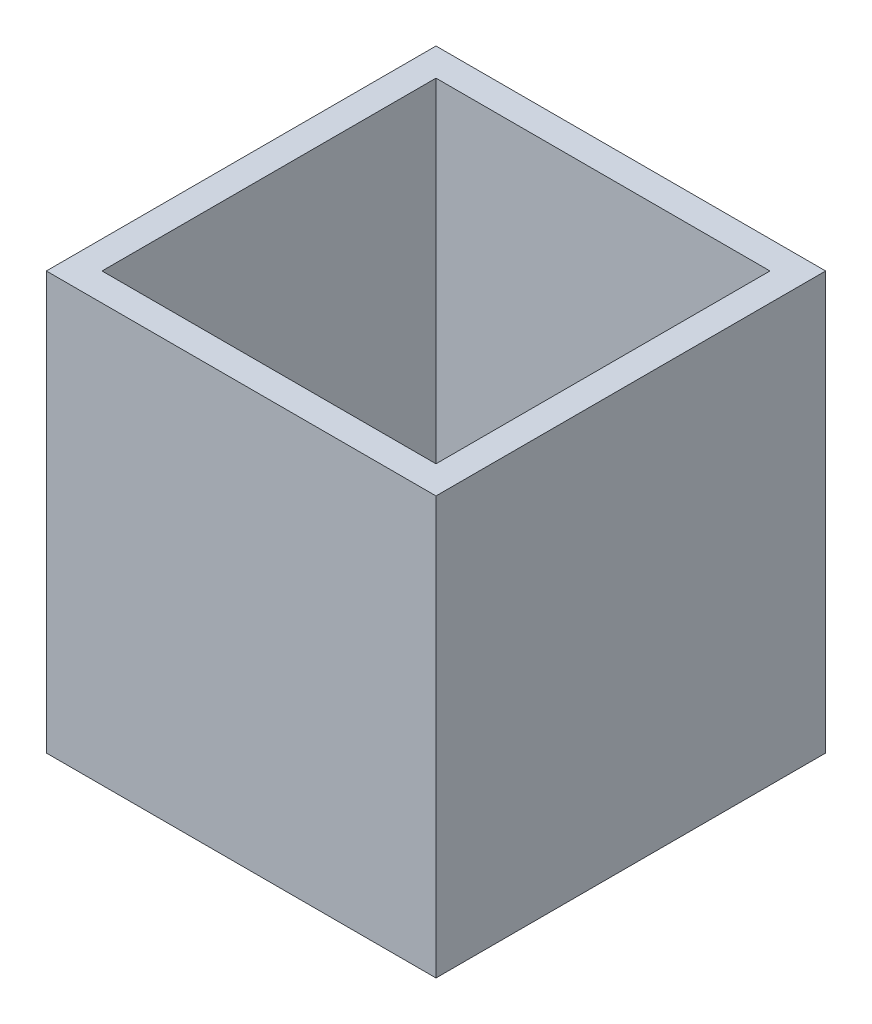
from build123d import *

# Parameters (mm, degrees)
SKETCH_1_W      = 28
SKETCH_1_H      = 28
SKETCH_1_W_2    = 24
SKETCH_1_H_2    = 24
EXTRUDE_1_DEPTH = 30


with BuildPart() as part:
    # Эскиз1 → Вытянуть-Тонкостенный1 (new body)
    with BuildSketch(Plane(origin=(0, 0, 0), x_dir=(1, 0, 0), z_dir=(0, 1, 0))):
        Rectangle(SKETCH_1_W, SKETCH_1_H)
        Rectangle(SKETCH_1_W_2, SKETCH_1_H_2, mode=Mode.SUBTRACT)
    extrude(amount=EXTRUDE_1_DEPTH)


solid = part.part
